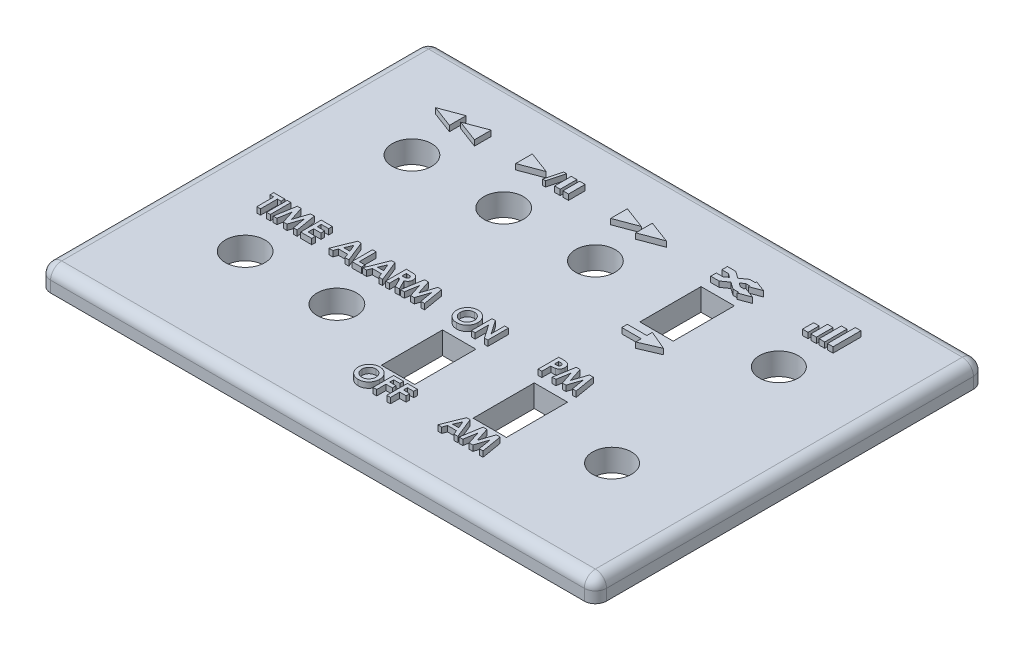
from build123d import *

# Parameters (mm, degrees)
SKETCH1_W           = 100
SKETCH1_H           = 70
BOSS_EXTRUDE1_DEPTH = 4
SKETCH2_R           = 3.55
SKETCH2_R_2         = 3.5
SKETCH2_W           = 6
SKETCH2_H           = 11
CUT_EXTRUDE1_DEPTH  = 5
SKETCH4_W           = 1
SKETCH4_H           = 3
SKETCH4_H_2         = 2
SKETCH4_H_3         = 4
SKETCH4_H_4         = 5
BOSS_EXTRUDE5_DEPTH = 1
SKETCH5_W           = 0.664850427
SKETCH5_H           = 3.704166667
BOSS_EXTRUDE6_DEPTH = 1
FILLET1_R           = 2


with BuildPart() as part:
    # Sketch1 → Boss-Extrude1 (new body)
    with BuildSketch(Plane(origin=(0, 0, 0), x_dir=(1, 0, 0), z_dir=(0, 1, 0))):
        Rectangle(SKETCH1_W, SKETCH1_H)
    extrude(amount=BOSS_EXTRUDE1_DEPTH)

    # Sketch2 → Cut-Extrude1 (cut, through all)
    with BuildSketch(Plane(origin=(0, 4, 0), x_dir=(1, 0, 0), z_dir=(0, 1, 0))):
        with Locations((-33, -15)):
            Circle(SKETCH2_R)
        with Locations((-16.5, -15)):
            Circle(SKETCH2_R)
        with Locations((33, -15)):
            Circle(SKETCH2_R_2)
        with Locations((-33, 15)):
            Circle(SKETCH2_R)
        with Locations((-16.5, 15)):
            Circle(SKETCH2_R)
        with Locations((0, 15)):
            Circle(SKETCH2_R)
        with Locations((33, 15)):
            Circle(SKETCH2_R_2)
        with Locations((16.5, 15)):
            Rectangle(SKETCH2_W, SKETCH2_H)
        with Locations((0, -15)):
            Rectangle(SKETCH2_W, SKETCH2_H)
        with Locations((16.5, -15)):
            Rectangle(SKETCH2_W, SKETCH2_H)
    extrude(amount=-CUT_EXTRUDE1_DEPTH, mode=Mode.SUBTRACT)

    # Sketch4 → Boss-Extrude5 (add)
    with BuildSketch(Plane(origin=(0, 4, 0), x_dir=(1, 0, 0), z_dir=(0, 1, 0))):
        Polygon((-33.25, 25), (-33.25, 22), (-37.25, 23.5), align=None)
        Polygon((-28.75, 25), (-28.75, 22), (-32.75, 23.5), align=None)
        Polygon((-21.339257166, 22), (-17.339257166, 23.5), (-21.339257166, 25), align=None)
        Polygon((-15.98236191, 22), (-16.5, 22), (-15.696152423, 25), (-15.178514333, 25), align=None)
        with Locations((-13.839257166, 23.5)):
            Rectangle(SKETCH4_W, SKETCH4_H)
        with Locations((-12.339257166, 23.5)):
            Rectangle(SKETCH4_W, SKETCH4_H)
        Polygon((-4.25, 25), (-4.25, 22), (-0.25, 23.5), align=None)
        Polygon((0.25, 25), (0.25, 22), (4.25, 23.5), align=None)
        Polygon((15.25, 25), (13.75, 25), (13.75, 24), (14.931270696, 24), (15.635953022, 23.5), (16.5, 24.113075528), align=None)
        Polygon((17.75, 25), (16.5, 24.113075528), (17.364046978, 23.5), (18.068729304, 24), (18.75, 24), (18.75, 23.75), (20.75, 24.5), (18.75, 25.25), (18.75, 25), align=None)
        Polygon((17.364046978, 23.5), (16.5, 24.113075528), (15.635953022, 23.5), (16.5, 22.886924472), align=None)
        Polygon((16.5, 22.886924472), (15.635953022, 23.5), (14.931270696, 23), (13.75, 23), (13.75, 22), (15.25, 22), align=None)
        Polygon((18.068729304, 23), (17.364046978, 23.5), (16.5, 22.886924472), (17.75, 22), (18.75, 22), (18.75, 21.75), (20.75, 22.5), (18.75, 23.25), (18.75, 23), align=None)
        Polygon((13.75, 6), (13.75, 7), (17.25, 7), (17.25, 8), (20.75, 6.5), (17.25, 5), (17.25, 6), align=None)
        with Locations((30.75, 23)):
            Rectangle(SKETCH4_W, SKETCH4_H_2)
        with Locations((32.25, 23.5)):
            Rectangle(SKETCH4_W, SKETCH4_H)
        with Locations((33.75, 24)):
            Rectangle(SKETCH4_W, SKETCH4_H_3)
        with Locations((35.25, 24.5)):
            Rectangle(SKETCH4_W, SKETCH4_H_4)
    extrude(amount=BOSS_EXTRUDE5_DEPTH)

    # Sketch5 → Boss-Extrude6 (add)
    with BuildSketch(Plane(origin=(0, 4, 0), x_dir=(1, 0, 0), z_dir=(0, 1, 0))):
        Polygon((-38.564373719, -4.295833333), (-36.569822437, -4.295833333), (-36.569822437, -4.960683761), (-37.234672864, -4.960683761), (-37.234672864, -8), (-37.899523291, -8), (-37.899523291, -4.960683761), (-38.564373719, -4.960683761), align=None)
        with Locations((-35.809993377, -6.147916667)):
            Rectangle(SKETCH5_W, SKETCH5_H)
        Polygon((-34.329662347, -4.295833333), (-33.639583221, -4.295833333), (-32.794421796, -6.879548945), (-31.943324206, -4.295833333), (-31.259923265, -4.295833333), (-30.633657907, -8), (-31.30667056, -8), (-31.702167522, -5.660409155), (-32.47238487, -8), (-33.120910845, -8), (-33.886676069, -5.660409155), (-34.28143101, -8), (-34.955185684, -8), align=None)
        Polygon((-30.016296796, -4.295833333), (-28.021745514, -4.295833333), (-28.021745514, -4.960683761), (-29.351446368, -4.960683761), (-29.351446368, -5.673023504), (-28.021745514, -5.673023504), (-28.021745514, -6.337873932), (-29.351446368, -6.337873932), (-29.351446368, -7.335149573), (-28.021745514, -7.335149573), (-28.021745514, -8), (-30.016296796, -8), align=None)
        Polygon((-23.448811507, -4.295833333), (-22.832192416, -4.295833333), (-21.336278955, -8), (-22.046392637, -8), (-22.334296616, -7.24017094), (-23.948191348, -7.24017094), (-24.236095328, -8), (-24.945466989, -8), align=None)
        Polygon((-23.140872972, -5.289398872), (-23.695904355, -6.575320513), (-22.585841588, -6.575320513), align=None, mode=Mode.SUBTRACT)
        Polygon((-20.790151818, -4.295833333), (-20.125301391, -4.295833333), (-20.125301391, -7.335149573), (-19.080536433, -7.335149573), (-19.080536433, -8), (-20.790151818, -8), align=None)
        Polygon((-17.370179028, -4.295833333), (-16.753559938, -4.295833333), (-15.257646476, -8), (-15.967760158, -8), (-16.255664138, -7.24017094), (-17.869558869, -7.24017094), (-18.157462849, -8), (-18.86683451, -8), align=None)
        Polygon((-17.062240493, -5.289398872), (-17.617271877, -6.575320513), (-16.50720911, -6.575320513), align=None, mode=Mode.SUBTRACT)
        with BuildLine():
            Line((-14.711519339, -4.295833333), (-13.936849868, -4.295833333))
            add(Edge.make_bspline(
                [(-13.936849868, -4.295833333), (-13.885644452, -4.296015083), (-13.787162013, -4.296364639), (-13.645155714, -4.301879709), (-13.5147034, -4.309554382), (-13.395611924, -4.321266136), (-13.287932235, -4.336794506), (-13.191556413, -4.355099884), (-13.106487274, -4.375962788), (-13.032007379, -4.401959612), (-12.964792956, -4.431283635), (-12.90213977, -4.464977475), (-12.842665597, -4.502665941), (-12.786767959, -4.545340718), (-12.733961091, -4.592234097), (-12.684145371, -4.643393282), (-12.63802474, -4.69925208), (-12.59588478, -4.759457536), (-12.557477598, -4.822792295), (-12.523533705, -4.889343316), (-12.495930474, -4.959156882), (-12.471540061, -5.031224034), (-12.453972437, -5.106574987), (-12.441754411, -5.184476187), (-12.43280885, -5.265201854), (-12.432294524, -5.320043289), (-12.43203216, -5.348018496)],
                knots=[0, 0, 0, 0, 0.000153605, 0.000295427, 0.000426277, 0.000545592, 0.000654308, 0.000752538, 0.000839823, 0.000916793, 0.000988895, 0.001059605, 0.001130003, 0.001199903, 0.001270336, 0.001341702, 0.001413907, 0.0014874, 0.001561973, 0.001635974, 0.001711208, 0.001786999, 0.00186403, 0.001942957, 0.00202351, 0.002107388, 0.002107388, 0.002107388, 0.002107388], degree=3))
            add(Edge.make_bspline(
                [(-12.43203216, -5.348018496), (-12.432713686, -5.377218187), (-12.434050036, -5.434473457), (-12.441248341, -5.518576781), (-12.454404583, -5.599040957), (-12.474331624, -5.675630399), (-12.49723517, -5.749298349), (-12.527691011, -5.81868559), (-12.562063438, -5.884801256), (-12.602886564, -5.946710118), (-12.647687952, -6.005787295), (-12.699791023, -6.059769321), (-12.755820299, -6.111557525), (-12.818925389, -6.157908071), (-12.886324564, -6.201955014), (-12.959356973, -6.241873274), (-13.037545981, -6.278666305), (-13.092516726, -6.299184641), (-13.120627245, -6.30967715)],
                knots=[0, 0, 0, 0, 8.7609e-05, 0.000171785, 0.000253028, 0.000331854, 0.000409056, 0.000484176, 0.000558859, 0.000632334, 0.000706395, 0.00078093, 0.000857099, 0.000935011, 0.001015485, 0.001098512, 0.00118449, 0.001274471, 0.001274471, 0.001274471, 0.001274471], degree=3))
            Line((-13.120627245, -6.30967715), (-12.265819553, -8))
            Line((-12.265819553, -8), (-13.004872037, -8))
            Line((-13.004872037, -8), (-13.82109466, -6.385363248))
            Line((-13.82109466, -6.385363248), (-14.046668912, -6.385363248))
            Line((-14.046668912, -6.385363248), (-14.046668912, -8))
            Line((-14.046668912, -8), (-14.711519339, -8))
            Line((-14.711519339, -8), (-14.711519339, -4.295833333))
        make_face()
        with BuildLine():
            Line((-14.046668912, -5.720512821), (-13.787703734, -5.720512821))
            add(Edge.make_bspline(
                [(-13.787703734, -5.720512821), (-13.756043089, -5.720156237), (-13.695419755, -5.719473456), (-13.60823544, -5.716306436), (-13.529051289, -5.708675483), (-13.457527259, -5.699034059), (-13.393303448, -5.687901642), (-13.33695271, -5.671948213), (-13.287606765, -5.65485371), (-13.245850365, -5.633609677), (-13.210174657, -5.609450604), (-13.179370966, -5.582005296), (-13.153891897, -5.550240847), (-13.132921323, -5.515020478), (-13.116608497, -5.476032672), (-13.104701384, -5.433705428), (-13.098047068, -5.387556584), (-13.097281466, -5.355707598), (-13.096882587, -5.339114249)],
                knots=[0, 0, 0, 0, 9.499e-05, 0.000181886, 0.000261628, 0.000333512, 0.000398421, 0.000456928, 0.000509039, 0.000554834, 0.000597025, 0.000638004, 0.000678101, 0.000718696, 0.000760592, 0.000804522, 0.000850275, 0.00090004, 0.00090004, 0.00090004, 0.00090004], degree=3))
            add(Edge.make_bspline(
                [(-13.096882587, -5.339114249), (-13.097636705, -5.319483107), (-13.099118029, -5.280921365), (-13.113817366, -5.225405978), (-13.137215535, -5.174022689), (-13.169288017, -5.127003661), (-13.209679139, -5.085783535), (-13.256031137, -5.049447666), (-13.3093444, -5.020715979), (-13.358708471, -5.001764864), (-13.403618236, -4.990426217), (-13.444147882, -4.981976757), (-13.491081457, -4.975988383), (-13.544454392, -4.969636645), (-13.604130638, -4.965517865), (-13.670435466, -4.962511977), (-13.743178449, -4.96128212), (-13.793887218, -4.960888957), (-13.820352639, -4.960683761)],
                knots=[0, 0, 0, 0, 5.8788e-05, 0.000115479, 0.000170932, 0.000227531, 0.000285256, 0.000343437, 0.000403545, 0.000466249, 0.000501525, 0.000542417, 0.000590373, 0.00064339, 0.000703658, 0.000769765, 0.000842498, 0.000921898, 0.000921898, 0.000921898, 0.000921898], degree=3))
            Line((-13.820352639, -4.960683761), (-14.046668912, -4.960683761))
            Line((-14.046668912, -4.960683761), (-14.046668912, -5.720512821))
        make_face(mode=Mode.SUBTRACT)
        Polygon((-11.426594293, -4.295833333), (-10.736515166, -4.295833333), (-9.891353741, -6.879548945), (-9.040256152, -4.295833333), (-8.35685521, -4.295833333), (-7.730589852, -8), (-8.403602506, -8), (-8.799099467, -5.660409155), (-9.569316815, -8), (-10.21784279, -8), (-10.983608014, -5.660409155), (-11.378362956, -8), (-12.05211763, -8), align=None)
        with BuildLine():
            add(Edge.make_bspline(
                [(-1.878218775, -4.200854701), (-1.813817298, -4.20252217), (-1.686674195, -4.205814133), (-1.499692572, -4.233255211), (-1.319501206, -4.277966513), (-1.146181578, -4.340118456), (-0.980167661, -4.421394432), (-0.820873869, -4.519490213), (-0.668870783, -4.636257298), (-0.52571601, -4.768971703), (-0.393415181, -4.913292824), (-0.278776436, -5.068680169), (-0.18101672, -5.231107496), (-0.099993205, -5.401010033), (-0.038278718, -5.579564437), (0.005028891, -5.765860316), (0.032851883, -5.959844671), (0.036051956, -6.091921577), (0.037678327, -6.159046975)],
                knots=[0, 0, 0, 0, 0.000193131, 0.000381284, 0.000565569, 0.000749353, 0.00093254, 0.001119111, 0.00130967, 0.001506585, 0.001704094, 0.001896132, 0.002084852, 0.002272053, 0.002459786, 0.002650387, 0.002845153, 0.003046437, 0.003046437, 0.003046437, 0.003046437], degree=3))
            add(Edge.make_bspline(
                [(0.037678327, -6.159046975), (0.035946312, -6.225416025), (0.03253332, -6.356198368), (0.006164747, -6.548395081), (-0.037872167, -6.732695343), (-0.098539928, -6.909516322), (-0.178093982, -7.078001559), (-0.273947278, -7.239226808), (-0.388629201, -7.391695859), (-0.517956851, -7.535326893), (-0.66033537, -7.665702876), (-0.811136825, -7.780596486), (-0.969664906, -7.877952995), (-1.13568758, -7.95772781), (-1.309560874, -8.019638106), (-1.490855299, -8.063320318), (-1.679559639, -8.08986688), (-1.80788774, -8.093257579), (-1.873024631, -8.094978632)],
                knots=[0, 0, 0, 0, 0.000199061, 0.000392256, 0.000580691, 0.000766778, 0.000952004, 0.001138688, 0.001328498, 0.001523412, 0.001717728, 0.001906798, 0.002091327, 0.002274859, 0.002458392, 0.002643942, 0.002833461, 0.003028815, 0.003028815, 0.003028815, 0.003028815], degree=3))
            add(Edge.make_bspline(
                [(-1.873024631, -8.094978632), (-1.941150008, -8.093434762), (-2.075007063, -8.090401269), (-2.270907461, -8.06155413), (-2.45859697, -8.018100261), (-2.63649889, -7.953247693), (-2.806424999, -7.872176531), (-2.967126801, -7.772332533), (-3.118550288, -7.653880701), (-3.259826872, -7.519854629), (-3.387823799, -7.37320071), (-3.500806194, -7.218273849), (-3.596109351, -7.056257553), (-3.673736756, -6.887075993), (-3.734935083, -6.711780592), (-3.77810355, -6.52930375), (-3.803604194, -6.340083113), (-3.807156285, -6.211560674), (-3.808956288, -6.146432626)],
                knots=[0, 0, 0, 0, 0.00020425, 0.000401323, 0.000592818, 0.000781292, 0.000968143, 0.001156756, 0.001347635, 0.001543938, 0.001740086, 0.001930808, 0.002118391, 0.002302992, 0.002488378, 0.002674476, 0.00286463, 0.003059984, 0.003059984, 0.003059984, 0.003059984], degree=3))
            add(Edge.make_bspline(
                [(-3.808956288, -6.146432626), (-3.808391344, -6.102617884), (-3.807268608, -6.015543197), (-3.793744072, -5.886502955), (-3.774272629, -5.759981405), (-3.745475288, -5.636482991), (-3.710493879, -5.515136489), (-3.665170522, -5.397071421), (-3.613580277, -5.281026529), (-3.553301933, -5.168372448), (-3.486278243, -5.060145689), (-3.413149429, -4.956856777), (-3.333731611, -4.859754626), (-3.24828062, -4.768201121), (-3.156501979, -4.682798049), (-3.059602943, -4.602336411), (-2.955704233, -4.528953555), (-2.847079867, -4.460857324), (-2.734342245, -4.399279083), (-2.617950309, -4.346865526), (-2.500301965, -4.30109366), (-2.379825589, -4.264968479), (-2.257812299, -4.235544897), (-2.132958631, -4.216086577), (-2.006392567, -4.202562416), (-1.921044766, -4.20142529), (-1.878218775, -4.200854701)],
                knots=[0, 0, 0, 0, 0.00013139, 0.000261116, 0.000388841, 0.000515202, 0.000641287, 0.000767389, 0.000894264, 0.001022066, 0.001150352, 0.001275944, 0.001401453, 0.001526399, 0.001651346, 0.001777325, 0.001903952, 0.00203263, 0.002161789, 0.002288969, 0.002415335, 0.002540211, 0.002666018, 0.002791544, 0.002919055, 0.003047478, 0.003047478, 0.003047478, 0.003047478], degree=3))
        make_face()
        with BuildLine():
            add(Edge.make_bspline(
                [(-1.888607063, -4.865705128), (-1.931949249, -4.866868096), (-2.017489379, -4.86916333), (-2.142961172, -4.886649907), (-2.263418525, -4.914577958), (-2.378193694, -4.955031398), (-2.487784125, -5.006518361), (-2.592384088, -5.068858944), (-2.69054509, -5.144196035), (-2.783576013, -5.228485122), (-2.867614143, -5.322402536), (-2.941864483, -5.423051017), (-3.004000057, -5.530262484), (-3.05603899, -5.643040968), (-3.095212774, -5.762654633), (-3.123115085, -5.888166533), (-3.140748304, -6.01979293), (-3.142970993, -6.109522474), (-3.144105861, -6.155336872)],
                knots=[0, 0, 0, 0, 0.000129989, 0.000256547, 0.000379294, 0.000500387, 0.000620883, 0.00074203, 0.00086491, 0.000991491, 0.001118125, 0.001242346, 0.001366048, 0.001489237, 0.001614304, 0.001742837, 0.001874543, 0.002011945, 0.002011945, 0.002011945, 0.002011945], degree=3))
            add(Edge.make_bspline(
                [(-3.144105861, -6.155336872), (-3.1426012, -6.206109532), (-3.139652312, -6.305615532), (-3.118903584, -6.450772203), (-3.083404576, -6.587858273), (-3.032144698, -6.716203273), (-2.968569002, -6.837232378), (-2.889618077, -6.949462206), (-2.796570554, -7.053564735), (-2.724887497, -7.114344127), (-2.688505233, -7.145192308)],
                knots=[0, 0, 0, 0, 0.000152295, 0.000298473, 0.000438856, 0.000576096, 0.000712192, 0.000848054, 0.000986766, 0.001129728, 0.001129728, 0.001129728, 0.001129728], degree=3))
            add(Edge.make_bspline(
                [(-2.688505233, -7.145192308), (-2.658701213, -7.167981759), (-2.599764664, -7.21304721), (-2.505689098, -7.270807831), (-2.408809791, -7.320314446), (-2.308395664, -7.360315205), (-2.204658789, -7.391779129), (-2.09761339, -7.413812798), (-1.987411143, -7.427640831), (-1.912887218, -7.429293543), (-1.875250693, -7.430128205)],
                knots=[0, 0, 0, 0, 0.000112494, 0.000222453, 0.000330636, 0.000438525, 0.000546271, 0.000655417, 0.000766045, 0.00087892, 0.00087892, 0.00087892, 0.00087892], degree=3))
            add(Edge.make_bspline(
                [(-1.875250693, -7.430128205), (-1.832653777, -7.428955376), (-1.748843006, -7.426647799), (-1.625706938, -7.409376491), (-1.507738845, -7.380147203), (-1.394206371, -7.340048634), (-1.285436893, -7.287915209), (-1.181961996, -7.223641016), (-1.083600263, -7.148015262), (-0.99068786, -7.062619275), (-0.905761532, -6.968331891), (-0.831666138, -6.867146562), (-0.767554962, -6.761292701), (-0.716598179, -6.649272109), (-0.675876729, -6.532142208), (-0.648310236, -6.409384254), (-0.630528056, -6.281504302), (-0.628304741, -6.194477475), (-0.6271721, -6.150142728)],
                knots=[0, 0, 0, 0, 0.000127766, 0.000251383, 0.000372141, 0.000491834, 0.000611977, 0.000733263, 0.000856592, 0.000983675, 0.001111357, 0.001236615, 0.001359417, 0.001481931, 0.001605127, 0.001730765, 0.001858793, 0.001991748, 0.001991748, 0.001991748, 0.001991748], degree=3))
            add(Edge.make_bspline(
                [(-0.6271721, -6.150142728), (-0.62834393, -6.106062919), (-0.6306505, -6.019298536), (-0.647952206, -5.891747362), (-0.676996129, -5.769531348), (-0.71721511, -5.652450903), (-0.768572618, -5.540391243), (-0.832081387, -5.433746436), (-0.907518572, -5.332619583), (-0.993147991, -5.237699824), (-1.086350351, -5.150474646), (-1.186412398, -5.074779047), (-1.290534282, -5.009001978), (-1.401105068, -4.957474879), (-1.51586257, -4.916423348), (-1.635507044, -4.886192411), (-1.760491652, -4.869286174), (-1.845521265, -4.86690945), (-1.888607063, -4.865705128)],
                knots=[0, 0, 0, 0, 0.000132213, 0.000260241, 0.000385326, 0.000508522, 0.000631036, 0.000754475, 0.000880174, 0.001008904, 0.001137539, 0.001262498, 0.001384806, 0.001506289, 0.001627629, 0.001750006, 0.001875829, 0.002005077, 0.002005077, 0.002005077, 0.002005077], degree=3))
        make_face(mode=Mode.SUBTRACT)
        Polygon((0.702528754, -4.295833333), (1.301339351, -4.295833333), (2.982015934, -6.733370893), (2.982015934, -4.295833333), (3.646866361, -4.295833333), (3.646866361, -8), (3.043603641, -8), (1.367379182, -5.569882646), (1.367379182, -8), (0.702528754, -8), align=None)
        with BuildLine():
            add(Edge.make_bspline(
                [(-1.878218775, -21.900854701), (-1.813817298, -21.90252217), (-1.686674195, -21.905814133), (-1.499692572, -21.933255211), (-1.319501206, -21.977966513), (-1.146181578, -22.040118456), (-0.980167661, -22.121394432), (-0.820873869, -22.219490213), (-0.668870783, -22.336257298), (-0.52571601, -22.468971703), (-0.393415181, -22.613292824), (-0.278776436, -22.768680169), (-0.18101672, -22.931107496), (-0.099993205, -23.101010033), (-0.038278718, -23.279564437), (0.005028891, -23.465860316), (0.032851883, -23.659844671), (0.036051956, -23.791921577), (0.037678327, -23.859046975)],
                knots=[0, 0, 0, 0, 0.000193131, 0.000381284, 0.000565569, 0.000749353, 0.00093254, 0.001119111, 0.00130967, 0.001506585, 0.001704094, 0.001896132, 0.002084852, 0.002272053, 0.002459786, 0.002650387, 0.002845153, 0.003046437, 0.003046437, 0.003046437, 0.003046437], degree=3))
            add(Edge.make_bspline(
                [(0.037678327, -23.859046975), (0.035946312, -23.925416025), (0.03253332, -24.056198368), (0.006164747, -24.248395081), (-0.037872167, -24.432695343), (-0.098539928, -24.609516322), (-0.178093982, -24.778001559), (-0.273947278, -24.939226808), (-0.388629201, -25.091695859), (-0.517956851, -25.235326893), (-0.66033537, -25.365702876), (-0.811136825, -25.480596486), (-0.969664906, -25.577952995), (-1.13568758, -25.65772781), (-1.309560874, -25.719638106), (-1.490855299, -25.763320318), (-1.679559639, -25.78986688), (-1.80788774, -25.793257579), (-1.873024631, -25.794978632)],
                knots=[0, 0, 0, 0, 0.000199061, 0.000392256, 0.000580691, 0.000766778, 0.000952004, 0.001138688, 0.001328498, 0.001523412, 0.001717728, 0.001906798, 0.002091327, 0.002274859, 0.002458392, 0.002643942, 0.002833461, 0.003028815, 0.003028815, 0.003028815, 0.003028815], degree=3))
            add(Edge.make_bspline(
                [(-1.873024631, -25.794978632), (-1.941150008, -25.793434762), (-2.075007063, -25.790401269), (-2.270907461, -25.76155413), (-2.45859697, -25.718100261), (-2.63649889, -25.653247693), (-2.806424999, -25.572176531), (-2.967126801, -25.472332533), (-3.118550288, -25.353880701), (-3.259826872, -25.219854629), (-3.387823799, -25.07320071), (-3.500806194, -24.918273849), (-3.596109351, -24.756257553), (-3.673736756, -24.587075993), (-3.734935083, -24.411780592), (-3.77810355, -24.22930375), (-3.803604194, -24.040083113), (-3.807156285, -23.911560674), (-3.808956288, -23.846432626)],
                knots=[0, 0, 0, 0, 0.00020425, 0.000401323, 0.000592818, 0.000781292, 0.000968143, 0.001156756, 0.001347635, 0.001543938, 0.001740086, 0.001930808, 0.002118391, 0.002302992, 0.002488378, 0.002674476, 0.00286463, 0.003059984, 0.003059984, 0.003059984, 0.003059984], degree=3))
            add(Edge.make_bspline(
                [(-3.808956288, -23.846432626), (-3.808391344, -23.802617884), (-3.807268608, -23.715543197), (-3.793744072, -23.586502955), (-3.774272629, -23.459981405), (-3.745475288, -23.336482991), (-3.710493879, -23.215136489), (-3.665170522, -23.097071421), (-3.613580277, -22.981026529), (-3.553301933, -22.868372448), (-3.486278243, -22.760145689), (-3.413149429, -22.656856777), (-3.333731611, -22.559754626), (-3.24828062, -22.468201121), (-3.156501979, -22.382798049), (-3.059602943, -22.302336411), (-2.955704233, -22.228953555), (-2.847079867, -22.160857324), (-2.734342245, -22.099279083), (-2.617950309, -22.046865526), (-2.500301965, -22.00109366), (-2.379825589, -21.964968479), (-2.257812299, -21.935544897), (-2.132958631, -21.916086577), (-2.006392567, -21.902562416), (-1.921044766, -21.90142529), (-1.878218775, -21.900854701)],
                knots=[0, 0, 0, 0, 0.00013139, 0.000261116, 0.000388841, 0.000515202, 0.000641287, 0.000767389, 0.000894264, 0.001022066, 0.001150352, 0.001275944, 0.001401453, 0.001526399, 0.001651346, 0.001777325, 0.001903952, 0.00203263, 0.002161789, 0.002288969, 0.002415335, 0.002540211, 0.002666018, 0.002791544, 0.002919055, 0.003047478, 0.003047478, 0.003047478, 0.003047478], degree=3))
        make_face()
        with BuildLine():
            add(Edge.make_bspline(
                [(-1.888607063, -22.565705128), (-1.931949249, -22.566868096), (-2.017489379, -22.56916333), (-2.142961172, -22.586649907), (-2.263418525, -22.614577958), (-2.378193694, -22.655031398), (-2.487784125, -22.706518361), (-2.592384088, -22.768858944), (-2.69054509, -22.844196035), (-2.783576013, -22.928485122), (-2.867614143, -23.022402536), (-2.941864483, -23.123051017), (-3.004000057, -23.230262484), (-3.05603899, -23.343040968), (-3.095212774, -23.462654633), (-3.123115085, -23.588166533), (-3.140748304, -23.71979293), (-3.142970993, -23.809522474), (-3.144105861, -23.855336872)],
                knots=[0, 0, 0, 0, 0.000129989, 0.000256547, 0.000379294, 0.000500387, 0.000620883, 0.00074203, 0.00086491, 0.000991491, 0.001118125, 0.001242346, 0.001366048, 0.001489237, 0.001614304, 0.001742837, 0.001874543, 0.002011945, 0.002011945, 0.002011945, 0.002011945], degree=3))
            add(Edge.make_bspline(
                [(-3.144105861, -23.855336872), (-3.1426012, -23.906109532), (-3.139652312, -24.005615532), (-3.118903584, -24.150772203), (-3.083404576, -24.287858273), (-3.032144698, -24.416203273), (-2.968569002, -24.537232378), (-2.889618077, -24.649462206), (-2.796570554, -24.753564735), (-2.724887497, -24.814344127), (-2.688505233, -24.845192308)],
                knots=[0, 0, 0, 0, 0.000152295, 0.000298473, 0.000438856, 0.000576096, 0.000712192, 0.000848054, 0.000986766, 0.001129728, 0.001129728, 0.001129728, 0.001129728], degree=3))
            add(Edge.make_bspline(
                [(-2.688505233, -24.845192308), (-2.658701213, -24.867981759), (-2.599764664, -24.91304721), (-2.505689098, -24.970807831), (-2.408809791, -25.020314446), (-2.308395664, -25.060315205), (-2.204658789, -25.091779129), (-2.09761339, -25.113812798), (-1.987411143, -25.127640831), (-1.912887218, -25.129293543), (-1.875250693, -25.130128205)],
                knots=[0, 0, 0, 0, 0.000112494, 0.000222453, 0.000330636, 0.000438525, 0.000546271, 0.000655417, 0.000766045, 0.00087892, 0.00087892, 0.00087892, 0.00087892], degree=3))
            add(Edge.make_bspline(
                [(-1.875250693, -25.130128205), (-1.832653777, -25.128955376), (-1.748843006, -25.126647799), (-1.625706938, -25.109376491), (-1.507738845, -25.080147203), (-1.394206371, -25.040048634), (-1.285436893, -24.987915209), (-1.181961996, -24.923641016), (-1.083600263, -24.848015262), (-0.99068786, -24.762619275), (-0.905761532, -24.668331891), (-0.831666138, -24.567146562), (-0.767554962, -24.461292701), (-0.716598179, -24.349272109), (-0.675876729, -24.232142208), (-0.648310236, -24.109384254), (-0.630528056, -23.981504302), (-0.628304741, -23.894477475), (-0.6271721, -23.850142728)],
                knots=[0, 0, 0, 0, 0.000127766, 0.000251383, 0.000372141, 0.000491834, 0.000611977, 0.000733263, 0.000856592, 0.000983675, 0.001111357, 0.001236615, 0.001359417, 0.001481931, 0.001605127, 0.001730765, 0.001858793, 0.001991748, 0.001991748, 0.001991748, 0.001991748], degree=3))
            add(Edge.make_bspline(
                [(-0.6271721, -23.850142728), (-0.62834393, -23.806062919), (-0.6306505, -23.719298536), (-0.647952206, -23.591747362), (-0.676996129, -23.469531348), (-0.71721511, -23.352450903), (-0.768572618, -23.240391243), (-0.832081387, -23.133746436), (-0.907518572, -23.032619583), (-0.993147991, -22.937699824), (-1.086350351, -22.850474646), (-1.186412398, -22.774779047), (-1.290534282, -22.709001978), (-1.401105068, -22.657474879), (-1.51586257, -22.616423348), (-1.635507044, -22.586192411), (-1.760491652, -22.569286174), (-1.845521265, -22.56690945), (-1.888607063, -22.565705128)],
                knots=[0, 0, 0, 0, 0.000132213, 0.000260241, 0.000385326, 0.000508522, 0.000631036, 0.000754475, 0.000880174, 0.001008904, 0.001137539, 0.001262498, 0.001384806, 0.001506289, 0.001627629, 0.001750006, 0.001875829, 0.002005077, 0.002005077, 0.002005077, 0.002005077], degree=3))
        make_face(mode=Mode.SUBTRACT)
        Polygon((0.702528754, -21.995833333), (2.507122772, -21.995833333), (2.507122772, -22.660683761), (1.367379182, -22.660683761), (1.367379182, -23.373023504), (2.507122772, -23.373023504), (2.507122772, -24.037873932), (1.367379182, -24.037873932), (1.367379182, -25.7), (0.702528754, -25.7), align=None)
        Polygon((3.171973199, -21.995833333), (4.976567216, -21.995833333), (4.976567216, -22.660683761), (3.836823626, -22.660683761), (3.836823626, -23.373023504), (4.976567216, -23.373023504), (4.976567216, -24.037873932), (3.836823626, -24.037873932), (3.836823626, -25.7), (3.171973199, -25.7), align=None)
        with BuildLine():
            Line((12.703743648, -4.295833333), (13.445764215, -4.295833333))
            add(Edge.make_bspline(
                [(13.445764215, -4.295833333), (13.494246876, -4.296050352), (13.587780092, -4.296469027), (13.722662685, -4.301546013), (13.847098481, -4.310644281), (13.961058891, -4.321888303), (14.064497058, -4.337651983), (14.157542518, -4.355723808), (14.240214578, -4.37774055), (14.313445491, -4.403874119), (14.37916787, -4.434684575), (14.441362437, -4.467499909), (14.49862359, -4.506663854), (14.55384147, -4.547955485), (14.603859178, -4.595319376), (14.651797116, -4.645603392), (14.695624983, -4.700801754), (14.73554586, -4.760246302), (14.771760246, -4.822838754), (14.803399557, -4.888691008), (14.829063595, -4.957907267), (14.850592531, -5.030039782), (14.867884782, -5.105085408), (14.879395055, -5.183505682), (14.887213411, -5.264753045), (14.887903273, -5.320050052), (14.888252195, -5.348018496)],
                knots=[0, 0, 0, 0, 0.000145444, 0.000280591, 0.000404828, 0.000519714, 0.000624026, 0.000718615, 0.000803935, 0.000880453, 0.000951505, 0.001021562, 0.001091122, 0.001159392, 0.001228176, 0.001297467, 0.001367693, 0.001439312, 0.001512113, 0.001584467, 0.0016582, 0.001733324, 0.001810187, 0.001888998, 0.001970957, 0.002054835, 0.002054835, 0.002054835, 0.002054835], degree=3))
            add(Edge.make_bspline(
                [(14.888252195, -5.348018496), (14.887747348, -5.37895932), (14.886755262, -5.439761842), (14.877029616, -5.528890878), (14.860415141, -5.613867345), (14.838700891, -5.695407864), (14.808421913, -5.772170913), (14.773829603, -5.845988081), (14.731270089, -5.914789761), (14.682639041, -5.979436581), (14.629528388, -6.040454149), (14.570677286, -6.096080698), (14.507207462, -6.146695432), (14.439486321, -6.192828798), (14.367259616, -6.234387735), (14.290579463, -6.271761397), (14.208922247, -6.30375446), (14.152058618, -6.320486572), (14.123228992, -6.328969685)],
                knots=[0, 0, 0, 0, 9.28e-05, 0.000182363, 0.000268515, 0.000352402, 0.000435084, 0.000515732, 0.00059667, 0.000677254, 0.000758226, 0.000839055, 0.000919826, 0.001001533, 0.001084642, 0.0011696, 0.001257237, 0.001347361, 0.001347361, 0.001347361, 0.001347361], degree=3))
            add(Edge.make_bspline(
                [(14.123228992, -6.328969685), (14.104240141, -6.333694142), (14.063104176, -6.343928836), (13.995035453, -6.35431962), (13.916593396, -6.363873307), (13.827524352, -6.372083544), (13.727776969, -6.377664593), (13.617447829, -6.382023143), (13.496486933, -6.385192259), (13.41237551, -6.385304714), (13.368594076, -6.385363248)],
                knots=[0, 0, 0, 0, 5.8676e-05, 0.000127111, 0.000206354, 0.00029577, 0.000395378, 0.000506029, 0.000627015, 0.000758354, 0.000758354, 0.000758354, 0.000758354], degree=3))
            Line((13.368594076, -6.385363248), (13.368594076, -8))
            Line((13.368594076, -8), (12.703743648, -8))
            Line((12.703743648, -8), (12.703743648, -4.295833333))
        make_face()
        with BuildLine():
            Line((13.368594076, -5.720512821), (13.603814595, -5.720512821))
            add(Edge.make_bspline(
                [(13.603814595, -5.720512821), (13.646616682, -5.720241422), (13.725373159, -5.719742045), (13.832926694, -5.71252076), (13.919358783, -5.701492401), (13.987641739, -5.685675182), (14.0415576, -5.661670458), (14.088056655, -5.633901513), (14.127940081, -5.598788445), (14.162473258, -5.558665756), (14.190081492, -5.512562776), (14.209226365, -5.461230201), (14.221662498, -5.405746585), (14.22281109, -5.36713366), (14.223401768, -5.347276476)],
                knots=[0, 0, 0, 0, 0.000128389, 0.000236237, 0.000323127, 0.000389715, 0.000445544, 0.000499503, 0.000551576, 0.000604213, 0.000657787, 0.000711807, 0.000767986, 0.000827463, 0.000827463, 0.000827463, 0.000827463], degree=3))
            add(Edge.make_bspline(
                [(14.223401768, -5.347276476), (14.222817166, -5.329927512), (14.221682897, -5.296266351), (14.213350249, -5.247684947), (14.200070405, -5.202397056), (14.180828422, -5.160875651), (14.155953095, -5.123191283), (14.125625036, -5.089358798), (14.090233415, -5.058653643), (14.062909015, -5.042400936), (14.049026935, -5.034143797)],
                knots=[0, 0, 0, 0, 5.2026e-05, 0.000100943, 0.000147425, 0.000193238, 0.000237691, 0.000282367, 0.000329208, 0.000377582, 0.000377582, 0.000377582, 0.000377582], degree=3))
            add(Edge.make_bspline(
                [(14.049026935, -5.034143797), (14.037268012, -5.028196972), (14.012371962, -5.015606326), (13.969971575, -5.000968779), (13.921042177, -4.988620396), (13.865253437, -4.978371357), (13.802827915, -4.970417038), (13.733776746, -4.964333974), (13.657998317, -4.961887737), (13.605298954, -4.961096155), (13.577843875, -4.960683761)],
                knots=[0, 0, 0, 0, 3.9495e-05, 8.3618e-05, 0.00013419, 0.000190803, 0.000253665, 0.000322928, 0.000398672, 0.00048105, 0.00048105, 0.00048105, 0.00048105], degree=3))
            Line((13.577843875, -4.960683761), (13.368594076, -4.960683761))
            Line((13.368594076, -4.960683761), (13.368594076, -5.720512821))
        make_face(mode=Mode.SUBTRACT)
        Polygon((15.846200746, -4.295833333), (16.536279873, -4.295833333), (17.381441298, -6.879548945), (18.232538887, -4.295833333), (18.915939829, -4.295833333), (19.542205187, -8), (18.869192533, -8), (18.473695572, -5.660409155), (17.703478224, -8), (17.054952249, -8), (16.289187025, -5.660409155), (15.894432083, -8), (15.220677409, -8), align=None)
        Polygon((13.844229259, -21.995833333), (14.460848349, -21.995833333), (15.956761811, -25.7), (15.246648129, -25.7), (14.958744149, -24.94017094), (13.344849418, -24.94017094), (13.056945438, -25.7), (12.347573777, -25.7), align=None)
        Polygon((14.152167794, -22.989398872), (13.59713641, -24.275320513), (14.707199177, -24.275320513), align=None, mode=Mode.SUBTRACT)
        Polygon((16.795987071, -21.995833333), (17.486066198, -21.995833333), (18.331227623, -24.579548945), (19.182325212, -21.995833333), (19.865726154, -21.995833333), (20.491991512, -25.7), (19.818978858, -25.7), (19.423481896, -23.360409155), (18.653264549, -25.7), (18.004738574, -25.7), (17.238973349, -23.360409155), (16.844218408, -25.7), (16.170463734, -25.7), align=None)
    extrude(amount=BOSS_EXTRUDE6_DEPTH)

    # Fillet1
    fillet1_edges = [part.edges().sort_by_distance(p)[0] for p in [
        (-50, 4, 0),
        (0, 4, 35),
        (50, 4, 0),
        (0, 4, -35),
        (50, 2, 35),
        (-50, 2, 35),
        (-50, 2, -35),
        (50, 2, -35),
    ]]
    fillet(fillet1_edges, radius=FILLET1_R)


solid = part.part
